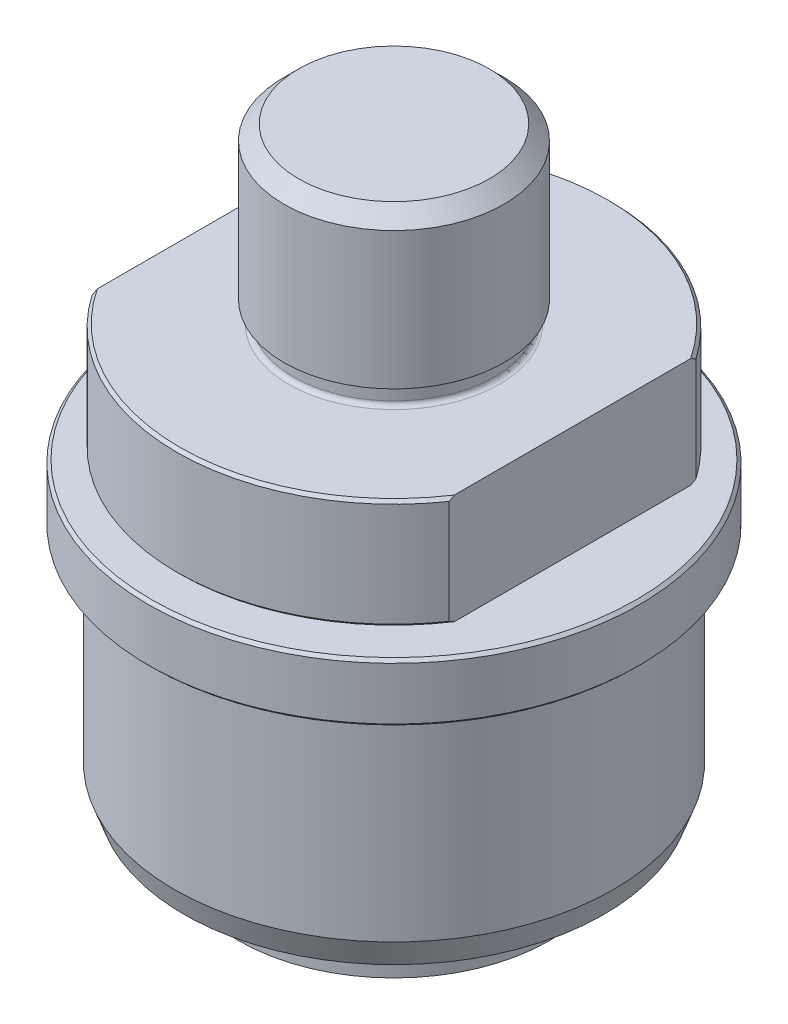
from build123d import *

# Parameters (mm, degrees)
CHAMFER1_SIZE      = 0.508
CHAMFER2_SIZE      = 2.54
CUT_EXTRUDE1_DEPTH = 80.121
CHAMFER3_SIZE      = 0.508
SKETCH3_R          = 1.4732
REVOLVE3_ANGLE     = 330


with BuildPart() as part:
    # Sketch1 → Revolve1 (revolve)
    with BuildSketch(Plane.XY, mode=Mode.PRIVATE) as revolve1_sk:
        with BuildLine():
            Line((0, 29.972), (0, -49.1744))
            Line((0, -49.1744), (8.636, -49.1744))
            Line((8.636, -49.1744), (20.0406, -60.579))
            Line((20.0406, -60.579), (20.0406, -77.597))
            ThreePointArc((20.0406, -77.597), (20.486969265, -78.674630735), (21.5646, -79.121))
            Line((21.5646, -79.121), (26.8605, -79.121))
            Line((26.8605, -79.121), (26.8605, -76.6826))
            ThreePointArc((26.8605, -76.6826), (25.3365, -75.1586), (26.8605, -73.6346))
            Line((26.8605, -73.6346), (26.8605, -18.9992))
            Line((26.8605, -18.9992), (37.5793, -18.9992))
            Line((37.5793, -18.9992), (37.5793, 0))
            Line((37.5793, 0), (18.2245, 0))
            ThreePointArc((18.2245, 0), (17.685684633, 0.223184633), (17.4625, 0.762))
            Line((17.4625, 0.762), (17.4625, 3.683))
            Line((17.4625, 3.683), (19.05, 3.683))
            Line((19.05, 3.683), (19.05, 29.972))
            Line((19.05, 29.972), (0, 29.972))
        make_face()
    revolve(revolve1_sk.sketch.rotate(Axis((0, 29.972, 0), (0, 1, 0)), 90), axis=Axis((0, 29.972, 0), (0, 1, 0)))  # turned: the seam where the file's is

    # Chamfer1
    chamfer1_edges = [part.edges().sort_by_distance(p)[0] for p in [
        (0, -18.9992, 37.5793),
        (0, 0, 37.5793),
    ]]
    chamfer(chamfer1_edges, length=CHAMFER1_SIZE)

    # Chamfer2
    chamfer2_edges = [part.edges().sort_by_distance(p)[0] for p in [
        (0, 29.972, 19.05),
    ]]
    chamfer(chamfer2_edges, length=CHAMFER2_SIZE)

    # Sketch4 → Cut-Extrude1 (cut, through all)
    with BuildSketch(Plane(origin=(0, 0, 0), x_dir=(1, 0, 0), z_dir=(0, 1, 0))):
        with BuildLine():
            Line((-30.9118, 21.369707748), (-30.9118, -21.369707748))
            ThreePointArc((-30.9118, -21.369707748), (-37.5793, 0), (-30.9118, 21.369707748))
        make_face()
        with BuildLine():
            Line((30.9118, 21.369707748), (30.9118, -21.369707748))
            ThreePointArc((30.9118, -21.369707748), (37.5793, 0), (30.9118, 21.369707748))
        make_face()
    extrude(amount=-CUT_EXTRUDE1_DEPTH, mode=Mode.SUBTRACT)


with BuildPart() as body_2:
    # Sketch2 → Revolve2 (revolve)
    with BuildSketch(Plane.XY, mode=Mode.PRIVATE) as revolve2_sk:
        with BuildLine():
            Line((26.9113, -20.3708), (26.9113, -64.3636))
            Line((26.9113, -64.3636), (31.0896, -64.3636))
            ThreePointArc((31.0896, -64.3636), (31.80802049, -64.66117951), (32.1056, -65.3796))
            Line((32.1056, -65.3796), (32.1056, -70.4088))
            Line((32.1056, -70.4088), (36.359728089, -70.4088))
            Line((36.359728089, -70.4088), (38.0238, -65.8368))
            Line((38.0238, -65.8368), (38.0238, -31.242))
            ThreePointArc((38.0238, -31.242), (38.246984633, -30.703184633), (38.7858, -30.48))
            Line((38.7858, -30.48), (42.5069, -30.48))
            Line((42.5069, -30.48), (42.5069, -20.3708))
            Line((42.5069, -20.3708), (26.9113, -20.3708))
        make_face()
    revolve(revolve2_sk.sketch.rotate(Axis((0, 0, 0), (0, 1, 0)), 90), axis=Axis((0, 0, 0), (0, 1, 0)))  # turned: the seam where the file's is

    # Chamfer3
    chamfer3_edges = [body_2.edges().sort_by_distance(p)[0] for p in [
        (0, -20.3708, 42.5069),
        (0, -30.48, 42.5069),
    ]]
    chamfer(chamfer3_edges, length=CHAMFER3_SIZE)


with BuildPart() as body_3:
    # Sketch3 → Revolve3 (revolve)
    with BuildSketch(Plane.XY):
        with Locations((26.8605, -75.1586)):
            Circle(SKETCH3_R)
    revolve(axis=Axis((0, 0, 0), (0, -1, 0)), revolution_arc=REVOLVE3_ANGLE)


solid = Compound([part.part, body_2.part, body_3.part])
